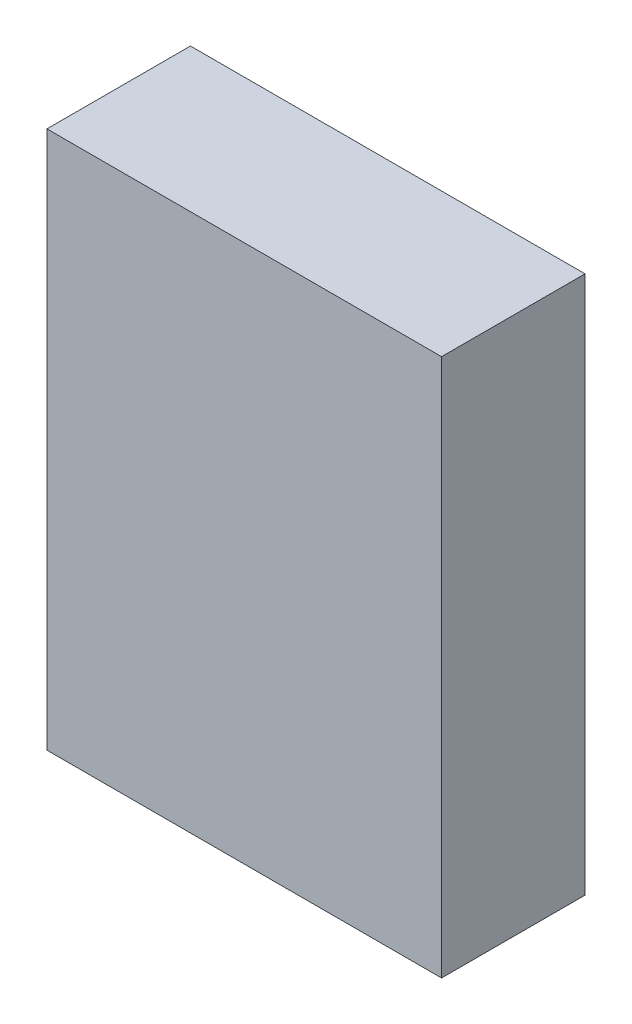
from build123d import *

# Parameters (mm, degrees)
ESQUISSE1_W        = 110
ESQUISSE1_H        = 150
BOSS_EXTRU_1_DEPTH = 40


with BuildPart() as part:
    # Esquisse1 → Boss.-Extru.1 (new body)
    with BuildSketch(Plane.XY):
        with Locations((2.230115498, -35.108205431)):
            Rectangle(ESQUISSE1_W, ESQUISSE1_H)
    extrude(amount=BOSS_EXTRU_1_DEPTH)


solid = part.part
